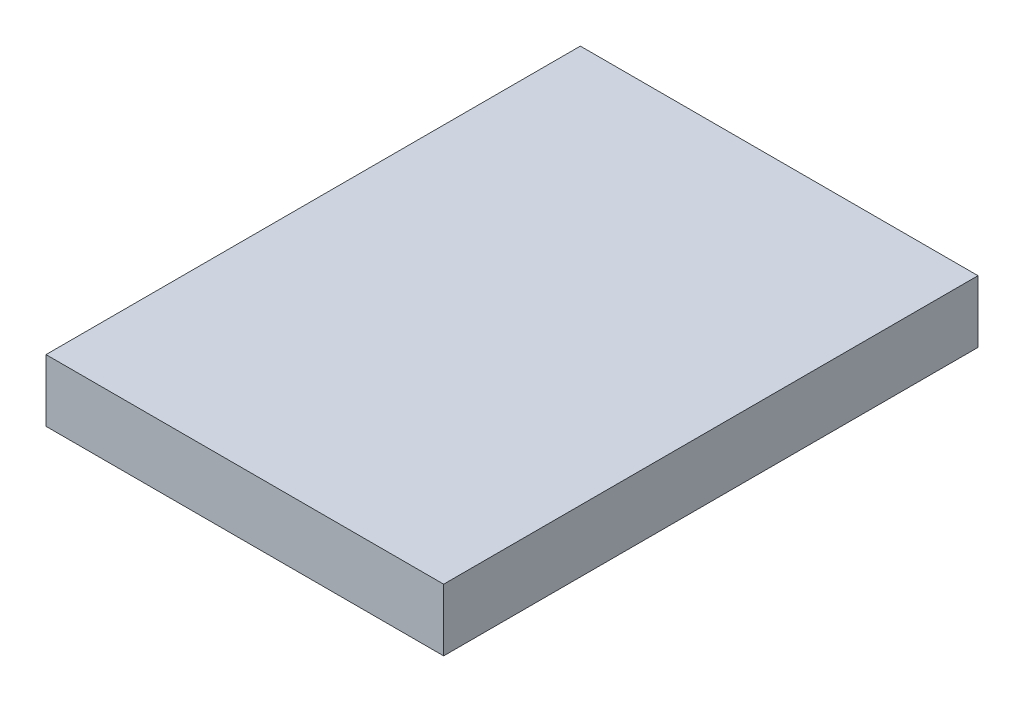
from build123d import *

# Parameters (mm, degrees)
SKETCH1_W           = 50.8
SKETCH1_H           = 68.2625
BOSS_EXTRUDE1_DEPTH = 7.9375


with BuildPart() as part:
    # Sketch1 → Boss-Extrude1 (new body)
    with BuildSketch(Plane(origin=(0, 0, 0), x_dir=(1, 0, 0), z_dir=(0, 1, 0))):
        with Locations((25.4, 34.13125)):
            Rectangle(SKETCH1_W, SKETCH1_H)
    extrude(amount=BOSS_EXTRUDE1_DEPTH)


solid = part.part
